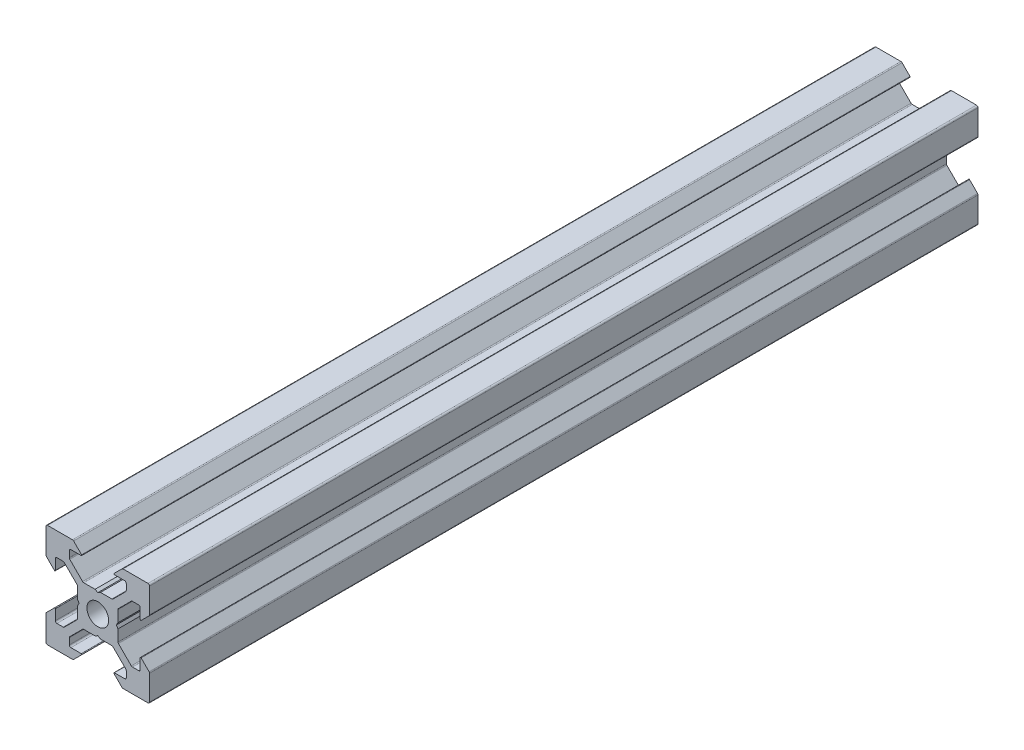
from build123d import *

# Parameters (mm, degrees)
BOSS_EXTRU_1_DEPTH = 160


with BuildPart() as part:
    # Esquisse1 → Boss.-Extru.1 (new body)
    with BuildSketch(Plane.XY):
        with BuildLine():
            Line((18.774857412, -2.895228684), (18.774857412, -4.894568513))
            ThreePointArc((18.774857412, -4.894568513), (18.686989447, -5.106700547), (18.474857412, -5.194568513))
            Line((18.474857412, -5.194568513), (17.259121481, -5.194568513))
            ThreePointArc((17.259121481, -5.194568513), (17.144316451, -5.171732372), (17.046989447, -5.106700547))
            Line((17.046989447, -5.106700547), (14.56338555, -2.62309665))
            ThreePointArc((14.56338555, -2.62309665), (14.498353724, -2.525769645), (14.475517584, -2.410964616))
            Line((14.475517584, -2.410964616), (14.475517584, -0.214843927))
            Line((14.475517584, -0.214843927), (14.175517584, 0.304771316))
            Line((14.175517584, 0.304771316), (14.475517584, 0.824386558))
            Line((14.475517584, 0.824386558), (14.475517584, 3.020507247))
            ThreePointArc((14.475517584, 3.020507247), (14.498353724, 3.135312277), (14.56338555, 3.232639281))
            Line((14.56338555, 3.232639281), (17.046989447, 5.716243178))
            ThreePointArc((17.046989447, 5.716243178), (17.144316451, 5.781275004), (17.259121481, 5.804111144))
            Line((17.259121481, 5.804111144), (18.474857412, 5.804111144))
            ThreePointArc((18.474857412, 5.804111144), (18.686989447, 5.716243178), (18.774857412, 5.504111144))
            Line((18.774857412, 5.504111144), (18.774857412, 3.504771316))
            ThreePointArc((18.774857412, 3.504771316), (18.836589069, 3.412383362), (18.94556809, 3.434060638))
            Line((18.94556809, 3.434060638), (20.486989447, 4.975481994))
            ThreePointArc((20.486989447, 4.975481994), (20.552021272, 5.072808998), (20.574857412, 5.187614028))
            Line((20.574857412, 5.187614028), (20.574857412, 10.004771316))
            ThreePointArc((20.574857412, 10.004771316), (20.486989447, 10.21690335), (20.274857412, 10.304771316))
            Line((20.274857412, 10.304771316), (15.457700125, 10.304771316))
            ThreePointArc((15.457700125, 10.304771316), (15.342895095, 10.281935175), (15.24556809, 10.21690335))
            Line((15.24556809, 10.21690335), (13.704146734, 8.675481994))
            ThreePointArc((13.704146734, 8.675481994), (13.682469459, 8.566502972), (13.774857412, 8.504771316))
            Line((13.774857412, 8.504771316), (15.77419724, 8.504771316))
            ThreePointArc((15.77419724, 8.504771316), (15.986329275, 8.41690335), (16.07419724, 8.204771316))
            Line((16.07419724, 8.204771316), (16.07419724, 6.989035384))
            ThreePointArc((16.07419724, 6.989035384), (16.0513611, 6.874230355), (15.986329275, 6.77690335))
            Line((15.986329275, 6.77690335), (13.502725378, 4.293299453))
            ThreePointArc((13.502725378, 4.293299453), (13.405398373, 4.228267628), (13.290593344, 4.205431487))
            Line((13.290593344, 4.205431487), (11.094472654, 4.205431487))
            Line((11.094472654, 4.205431487), (10.574857412, 3.905431487))
            Line((10.574857412, 3.905431487), (10.05524217, 4.205431487))
            Line((10.05524217, 4.205431487), (7.859121481, 4.205431487))
            ThreePointArc((7.859121481, 4.205431487), (7.744316451, 4.228267628), (7.646989447, 4.293299453))
            Line((7.646989447, 4.293299453), (5.16338555, 6.77690335))
            ThreePointArc((5.16338555, 6.77690335), (5.098353724, 6.874230355), (5.075517584, 6.989035384))
            Line((5.075517584, 6.989035384), (5.075517584, 8.204771316))
            ThreePointArc((5.075517584, 8.204771316), (5.16338555, 8.41690335), (5.375517584, 8.504771316))
            Line((5.375517584, 8.504771316), (7.374857412, 8.504771316))
            ThreePointArc((7.374857412, 8.504771316), (7.467245365, 8.566502972), (7.44556809, 8.675481994))
            Line((7.44556809, 8.675481994), (5.904146734, 10.21690335))
            ThreePointArc((5.904146734, 10.21690335), (5.806819729, 10.281935175), (5.6920147, 10.304771316))
            Line((5.6920147, 10.304771316), (0.874857412, 10.304771316))
            ThreePointArc((0.874857412, 10.304771316), (0.662725378, 10.21690335), (0.574857412, 10.004771316))
            Line((0.574857412, 10.004771316), (0.574857412, 5.187614028))
            ThreePointArc((0.574857412, 5.187614028), (0.597693552, 5.072808998), (0.662725378, 4.975481994))
            Line((0.662725378, 4.975481994), (2.204146734, 3.434060638))
            ThreePointArc((2.204146734, 3.434060638), (2.313125755, 3.412383362), (2.374857412, 3.504771316))
            Line((2.374857412, 3.504771316), (2.374857412, 5.504111144))
            ThreePointArc((2.374857412, 5.504111144), (2.462725378, 5.716243178), (2.674857412, 5.804111144))
            Line((2.674857412, 5.804111144), (3.890593344, 5.804111144))
            ThreePointArc((3.890593344, 5.804111144), (4.005398373, 5.781275004), (4.102725378, 5.716243178))
            Line((4.102725378, 5.716243178), (6.586329275, 3.232639281))
            ThreePointArc((6.586329275, 3.232639281), (6.6513611, 3.135312277), (6.67419724, 3.020507247))
            Line((6.67419724, 3.020507247), (6.67419724, 0.824386558))
            Line((6.67419724, 0.824386558), (6.97419724, 0.304771316))
            Line((6.97419724, 0.304771316), (6.67419724, -0.214843927))
            Line((6.67419724, -0.214843927), (6.67419724, -2.410964616))
            ThreePointArc((6.67419724, -2.410964616), (6.6513611, -2.525769645), (6.586329275, -2.62309665))
            Line((6.586329275, -2.62309665), (4.102725378, -5.106700547))
            ThreePointArc((4.102725378, -5.106700547), (4.005398373, -5.171732372), (3.890593344, -5.194568513))
            Line((3.890593344, -5.194568513), (2.674857412, -5.194568513))
            ThreePointArc((2.674857412, -5.194568513), (2.462725378, -5.106700547), (2.374857412, -4.894568513))
            Line((2.374857412, -4.894568513), (2.374857412, -2.895228684))
            ThreePointArc((2.374857412, -2.895228684), (2.313125755, -2.802840731), (2.204146734, -2.824518006))
            Line((2.204146734, -2.824518006), (0.662725378, -4.365939362))
            ThreePointArc((0.662725378, -4.365939362), (0.597693552, -4.463266367), (0.574857412, -4.578071397))
            Line((0.574857412, -4.578071397), (0.574857412, -9.395228684))
            ThreePointArc((0.574857412, -9.395228684), (0.662725378, -9.607360719), (0.874857412, -9.695228684))
            Line((0.874857412, -9.695228684), (5.6920147, -9.695228684))
            ThreePointArc((5.6920147, -9.695228684), (5.806819729, -9.672392544), (5.904146734, -9.607360719))
            Line((5.904146734, -9.607360719), (7.44556809, -8.065939362))
            ThreePointArc((7.44556809, -8.065939362), (7.467245365, -7.956960341), (7.374857412, -7.895228684))
            Line((7.374857412, -7.895228684), (5.375517584, -7.895228684))
            ThreePointArc((5.375517584, -7.895228684), (5.16338555, -7.807360719), (5.075517584, -7.595228684))
            Line((5.075517584, -7.595228684), (5.075517584, -6.379492753))
            ThreePointArc((5.075517584, -6.379492753), (5.098353724, -6.264687723), (5.16338555, -6.167360719))
            Line((5.16338555, -6.167360719), (7.646989447, -3.683756822))
            ThreePointArc((7.646989447, -3.683756822), (7.744316451, -3.618724996), (7.859121481, -3.595888856))
            Line((7.859121481, -3.595888856), (10.05524217, -3.595888856))
            Line((10.05524217, -3.595888856), (10.574857412, -3.295888856))
            Line((10.574857412, -3.295888856), (11.094472654, -3.595888856))
            Line((11.094472654, -3.595888856), (13.290593344, -3.595888856))
            ThreePointArc((13.290593344, -3.595888856), (13.405398373, -3.618724996), (13.502725378, -3.683756822))
            Line((13.502725378, -3.683756822), (15.986329275, -6.167360719))
            ThreePointArc((15.986329275, -6.167360719), (16.0513611, -6.264687723), (16.07419724, -6.379492753))
            Line((16.07419724, -6.379492753), (16.07419724, -7.595228684))
            ThreePointArc((16.07419724, -7.595228684), (15.986329275, -7.807360719), (15.77419724, -7.895228684))
            Line((15.77419724, -7.895228684), (13.774857412, -7.895228684))
            ThreePointArc((13.774857412, -7.895228684), (13.682469459, -7.956960341), (13.704146734, -8.065939362))
            Line((13.704146734, -8.065939362), (15.24556809, -9.607360719))
            ThreePointArc((15.24556809, -9.607360719), (15.342895095, -9.672392544), (15.457700125, -9.695228684))
            Line((15.457700125, -9.695228684), (20.274857412, -9.695228684))
            ThreePointArc((20.274857412, -9.695228684), (20.486989447, -9.607360719), (20.574857412, -9.395228684))
            Line((20.574857412, -9.395228684), (20.574857412, -4.578071397))
            ThreePointArc((20.574857412, -4.578071397), (20.552021272, -4.463266367), (20.486989447, -4.365939362))
            Line((20.486989447, -4.365939362), (18.94556809, -2.824518006))
            ThreePointArc((18.94556809, -2.824518006), (18.836589069, -2.802840731), (18.774857412, -2.895228684))
        make_face()
        with BuildLine():
            ThreePointArc((10.574857412, -1.795228684), (12.059781653, -1.180152925), (12.674857412, 0.304771316))
            ThreePointArc((12.674857412, 0.304771316), (12.059781653, 1.789695556), (10.574857412, 2.404771316))
            ThreePointArc((10.574857412, 2.404771316), (9.089933172, 1.789695556), (8.474857412, 0.304771316))
            ThreePointArc((8.474857412, 0.304771316), (9.089933172, -1.180152925), (10.574857412, -1.795228684))
        make_face(mode=Mode.SUBTRACT)
    extrude(amount=BOSS_EXTRU_1_DEPTH)


solid = part.part
